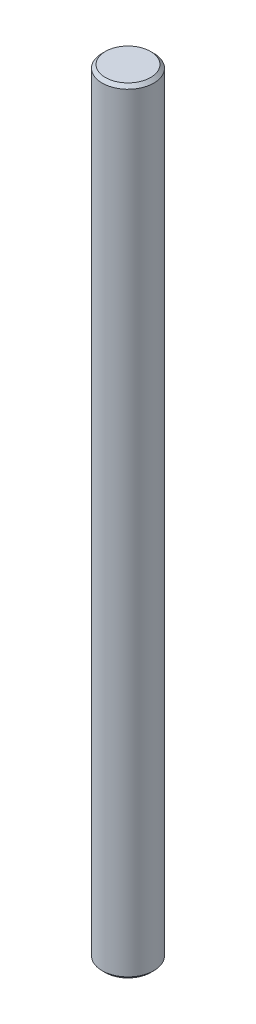
from build123d import *

# Parameters (mm, degrees)
SKETCH1_R           = 2
BOSS_EXTRUDE1_DEPTH = 30
CHAMFER1_SIZE       = 0.25


with BuildPart() as part:
    # Sketch1 → Boss-Extrude1 (new body, symmetric)
    with BuildSketch(Plane(origin=(0, 0, 0), x_dir=(1, 0, 0), z_dir=(0, 1, 0))):
        Circle(SKETCH1_R)
    extrude(amount=BOSS_EXTRUDE1_DEPTH, both=True)

    # Chamfer1
    chamfer1_edges = [part.edges().sort_by_distance(p)[0] for p in [
        (-2, -30, 0),
        (-2, 30, 0),
    ]]
    chamfer(chamfer1_edges, length=CHAMFER1_SIZE)


solid = part.part
